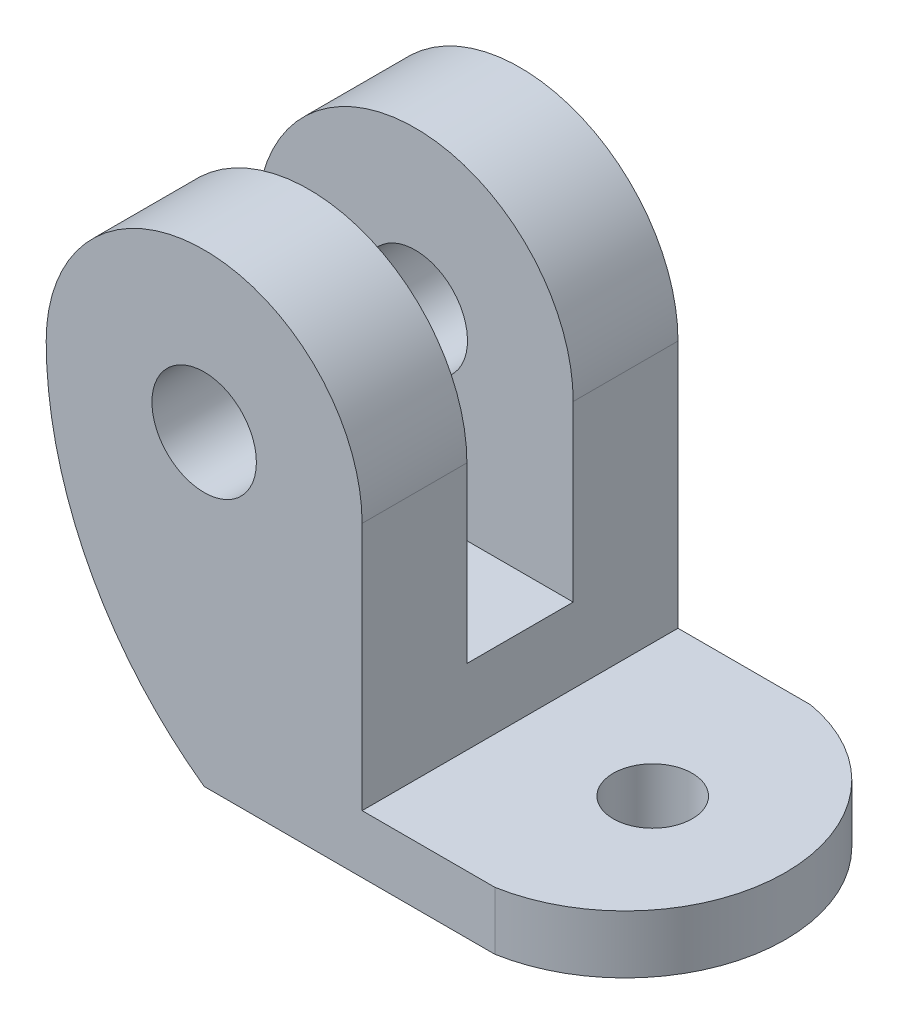
from build123d import *

# Parameters (mm, degrees)
SKETCH1_R           = 1.575
BOSS_EXTRUDE1_DEPTH = 9.525
CUT_EXTRUDE4_REACH  = 11.525
SKETCH2_W           = 3.205
SKETCH2_H           = 10
SKETCH4_R           = 1.190625
CUT_EXTRUDE5_DEPTH  = 1.75


with BuildPart() as part:
    # Sketch1 → Boss-Extrude1 (new body)
    with BuildSketch(Plane.XY):
        with BuildLine():
            Line((4.7625, 9.25), (4.7625, 1.75))
            Line((4.7625, 1.75), (12.7625, 1.75))
            Line((12.7625, 1.75), (12.7625, 0))
            Line((12.7625, 0), (0, 0))
            ThreePointArc((0, 0), (-3.501964629, 4.047983414), (-4.7625, 9.25))
            ThreePointArc((-4.7625, 9.25), (0, 14.0125), (4.7625, 9.25))
        make_face()
        with Locations((0, 9.25)):
            Circle(SKETCH1_R, mode=Mode.SUBTRACT)
    extrude(amount=BOSS_EXTRUDE1_DEPTH)

    # Sketch2 → Cut-Extrude4 (cut, up to next)
    with BuildSketch(Plane.ZY.offset(-4.7625), mode=Mode.PRIVATE) as cut_extrude4_sk1:
        with Locations((4.7625, 9.0125)):
            Rectangle(SKETCH2_W, SKETCH2_H)
    cut_extrude4_tool1 = extrude(cut_extrude4_sk1.sketch, amount=CUT_EXTRUDE4_REACH, mode=Mode.PRIVATE) & part.part
    add(cut_extrude4_tool1.solids().sort_by_distance((4.7625, 9.0125, 4.7625))[0], mode=Mode.SUBTRACT)

    # Sketch4 → Cut-Extrude5 (cut)
    with BuildSketch(Plane(origin=(0, 1.75, 0), x_dir=(1, 0, 0), z_dir=(0, 1, 0))):
        with BuildLine():
            Line((12.7625, -9.525), (12.7625, -4.7625))
            ThreePointArc((12.7625, -4.7625), (11.62983327, -7.872218888), (8.7625, -9.525))
            Line((8.7625, -9.525), (12.7625, -9.525))
        make_face()
        with BuildLine():
            Line((12.7625, 0), (8.7625, 0))
            ThreePointArc((8.7625, 0), (11.62983327, -1.652781112), (12.7625, -4.7625))
            Line((12.7625, -4.7625), (12.7625, 0))
        make_face()
        with Locations((8.7625, -4.7625)):
            Circle(SKETCH4_R)
    extrude(amount=-CUT_EXTRUDE5_DEPTH, mode=Mode.SUBTRACT)


solid = part.part
